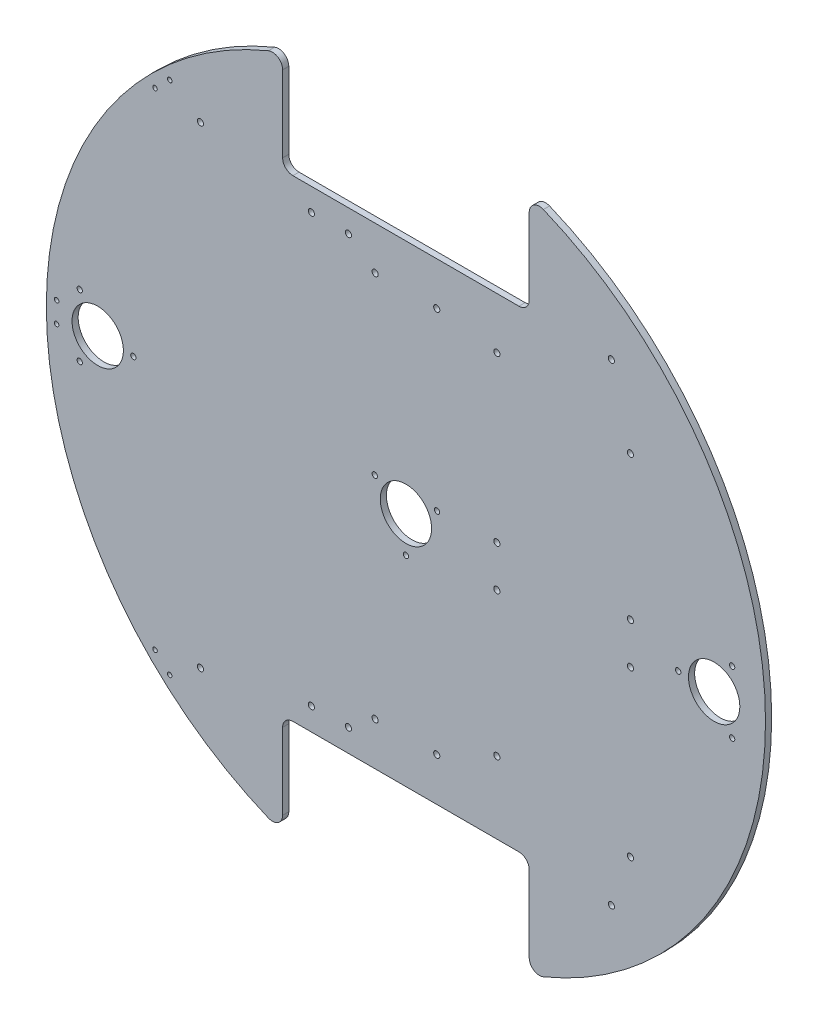
from build123d import *

# Parameters (mm, degrees)
SKETCH_1_R           = 175
EXTRUDE_1_DEPTH      = 3
CUT_EXTRUDE_1_DEPTH  = 3
FILLET_1_R           = 5
FILLET_2_R           = 5
FILLET_3_R           = 5
SKETCH_5_R           = 1.5
CUT_EXTRUDE_4_DEPTH  = 3
SKETCH_10_R          = 12.5
SKETCH_10_R_2        = 1.3
CUT_EXTRUDE_13_DEPTH = 10
SKETCH_14_R          = 1.1
CUT_EXTRUDE_14_DEPTH = 10
SKETCH_12_R          = 1.5
CUT_EXTRUDE_17_DEPTH = 10
SKETCH_13_R          = 1.5
CUT_EXTRUDE_18_DEPTH = 5
SKETCH_15_R          = 1.5
CUT_EXTRUDE_19_DEPTH = 4


with BuildPart() as part:
    # ｽｹｯﾁ1 → ﾎﾞｽ - 押し出し1 (new body)
    with BuildSketch(Plane.XY):
        Circle(SKETCH_1_R)
    extrude(amount=EXTRUDE_1_DEPTH)

    # ｽｹｯﾁ2 → ｶｯﾄ - 押し出し1 (cut)
    with BuildSketch(Plane.XY.offset(3)):
        with BuildLine():
            Line((-60, 115), (0, 115))
            Line((0, 115), (0, 175))
            ThreePointArc((0, 175), (-30.465194158, 172.327803749), (-60, 164.392822228))
            Line((-60, 164.392822228), (-60, 115))
        make_face()
        with BuildLine():
            Line((0, 175), (0, 115))
            Line((0, 115), (60, 115))
            Line((60, 115), (60, 164.392822228))
            ThreePointArc((60, 164.392822228), (30.465194158, 172.327803749), (0, 175))
        make_face()
        with BuildLine():
            Line((0, -175), (0, -115))
            Line((0, -115), (-60, -115))
            Line((-60, -115), (-60, -164.392822228))
            ThreePointArc((-60, -164.392822228), (-30.465194158, -172.327803749), (0, -175))
        make_face()
        with BuildLine():
            Line((60, -115), (0, -115))
            Line((0, -115), (0, -175))
            ThreePointArc((0, -175), (30.465194158, -172.327803749), (60, -164.392822228))
            Line((60, -164.392822228), (60, -115))
        make_face()
    extrude(amount=-CUT_EXTRUDE_1_DEPTH, mode=Mode.SUBTRACT)

    # ﾌｨﾚｯﾄ1
    fillet_1_edges = [part.edges().sort_by_distance(p)[0] for p in [
        (-60, 164.392822228, 1.5),
    ]]
    fillet(fillet_1_edges, radius=FILLET_1_R)

    # ﾌｨﾚｯﾄ2
    fillet_2_edges = [part.edges().sort_by_distance(p)[0] for p in [
        (-60, 115, 1.5),
        (60, 164.392822228, 1.5),
        (60, 115, 1.5),
    ]]
    fillet(fillet_2_edges, radius=FILLET_2_R)

    # ﾌｨﾚｯﾄ3
    fillet_3_edges = [part.edges().sort_by_distance(p)[0] for p in [
        (-60, -115, 1.5),
        (60, -115, 1.5),
        (60, -164.392822228, 1.5),
        (-60, -164.392822228, 1.5),
    ]]
    fillet(fillet_3_edges, radius=FILLET_3_R)

    # ｽｹｯﾁ5 → ｶｯﾄ - 押し出し4 (cut)
    with BuildSketch(Plane.XY.offset(3)):
        with Locations((-100, -115)):
            Circle(SKETCH_5_R)
        with Locations((100, -115)):
            Circle(SKETCH_5_R)
        with Locations((100, 115)):
            Circle(SKETCH_5_R)
        with Locations((-100, 115)):
            Circle(SKETCH_5_R)
    extrude(amount=-CUT_EXTRUDE_4_DEPTH, mode=Mode.SUBTRACT)

    # ｽｹｯﾁ10 → ｶｯﾄ - 押し出し13 (cut)
    with BuildSketch(Plane.XY.offset(3)):
        with Locations((-150, 0)):
            Circle(SKETCH_10_R)
        with Locations((150, 0)):
            Circle(SKETCH_10_R)
        Circle(SKETCH_10_R)
        with Locations((132.5, 0)):
            Circle(SKETCH_10_R_2)
        with Locations((158.75, 15.155444566)):
            Circle(SKETCH_10_R_2)
        with Locations((158.75, -15.155444566)):
            Circle(SKETCH_10_R_2)
        with Locations((-15.155444566, 8.75)):
            Circle(SKETCH_10_R_2)
        with Locations((15.155444566, 8.75)):
            Circle(SKETCH_10_R_2)
        with Locations((0, -17.5)):
            Circle(SKETCH_10_R_2)
        with Locations((-158.75, 15.155444566)):
            Circle(SKETCH_10_R_2)
        with Locations((-158.75, -15.155444566)):
            Circle(SKETCH_10_R_2)
        with Locations((-132.632898389, 0)):
            Circle(SKETCH_10_R_2)
    extrude(amount=-CUT_EXTRUDE_13_DEPTH, mode=Mode.SUBTRACT)

    # ｽｹｯﾁ14 → ｶｯﾄ - 押し出し14 (cut)
    with BuildSketch(Plane.XY.offset(3)):
        with Locations((-170, 5)):
            Circle(SKETCH_14_R)
        with Locations((-170, -5)):
            Circle(SKETCH_14_R)
        with Locations((-114.933514447, 125.360628815)):
            Circle(SKETCH_14_R)
        with Locations((-122.102620524, 118.388977786)):
            Circle(SKETCH_14_R)
        with Locations((-122.102620524, -118.388977786)):
            Circle(SKETCH_14_R)
        with Locations((-114.933514447, -125.360628815)):
            Circle(SKETCH_14_R)
    extrude(amount=-CUT_EXTRUDE_14_DEPTH, mode=Mode.SUBTRACT)

    # ｽｹｯﾁ12 → ｶｯﾄ - 押し出し17 (cut)
    with BuildSketch(Plane.XY.offset(3)):
        with Locations((-15, 94)):
            Circle(SKETCH_12_R)
        with Locations((15, 94)):
            Circle(SKETCH_12_R)
        with Locations((-15, -94)):
            Circle(SKETCH_12_R)
        with Locations((15, -94)):
            Circle(SKETCH_12_R)
    extrude(amount=-CUT_EXTRUDE_17_DEPTH, mode=Mode.SUBTRACT)

    # ｽｹｯﾁ13 → ｶｯﾄ - 押し出し18 (cut)
    with BuildSketch(Plane.XY.offset(3)):
        with Locations((-28, -104)):
            Circle(SKETCH_13_R)
        with Locations((-46, -104)):
            Circle(SKETCH_13_R)
        with Locations((-46, 104)):
            Circle(SKETCH_13_R)
        with Locations((-28, 104)):
            Circle(SKETCH_13_R)
    extrude(amount=-CUT_EXTRUDE_18_DEPTH, mode=Mode.SUBTRACT)

    # ｽｹｯﾁ15 → ｶｯﾄ - 押し出し19 (cut, through all)
    with BuildSketch(Plane.XY.offset(3)):
        with Locations((44.252990552, 10)):
            Circle(SKETCH_15_R)
        with Locations((44.252990552, 90)):
            Circle(SKETCH_15_R)
        with Locations((109.252990552, 10)):
            Circle(SKETCH_15_R)
        with Locations((109.252990552, 80)):
            Circle(SKETCH_15_R)
        with Locations((44.252990552, -10)):
            Circle(SKETCH_15_R)
        with Locations((109.252990552, -10)):
            Circle(SKETCH_15_R)
        with Locations((44.252990552, -80)):
            Circle(SKETCH_15_R)
        with Locations((109.252990552, -90)):
            Circle(SKETCH_15_R)
    extrude(amount=-CUT_EXTRUDE_19_DEPTH, mode=Mode.SUBTRACT)


solid = part.part
